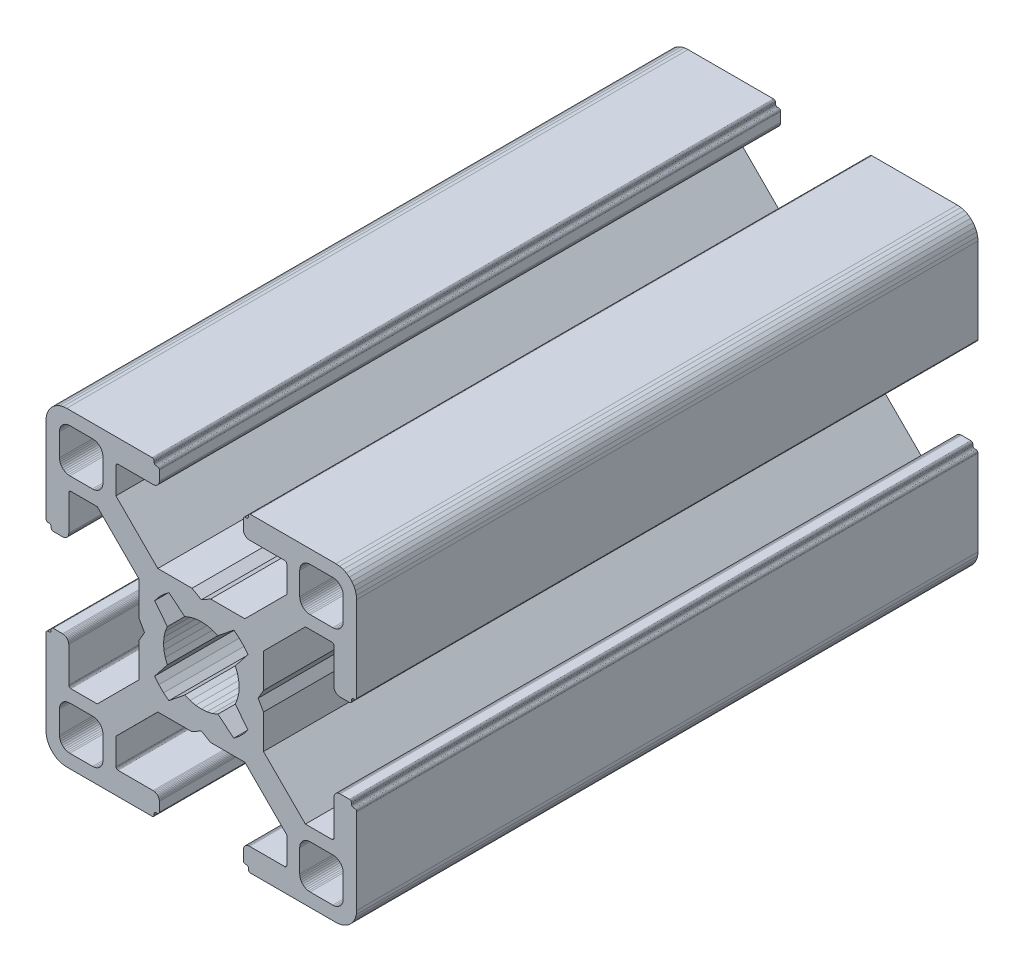
from build123d import *

# Parameters (mm, degrees)
BOSS_EXTRUDE1_DEPTH = 60


with BuildPart() as part:
    # Sketch1 → Boss-Extrude1 (new body)
    with BuildSketch(Plane.XY):
        Polygon((28.34729664, 29.969613999), (28.000000864, 29.999999329), (19.750000909, 29.999999329), (19.715268165, 29.996961355), (19.681595266, 29.987938702), (19.649999216, 29.973205179), (19.621443003, 29.953207821), (19.596790895, 29.928557575), (19.576793537, 29.899999499), (19.562061876, 29.868405312), (19.55303736, 29.834728688), (19.549999386, 29.799999669), (19.549999386, 29.699999839), (19.546961412, 29.665268958), (19.537936896, 29.631596059), (19.523203373, 29.599998146), (19.503207877, 29.571441934), (19.478557631, 29.546789825), (19.449999556, 29.526794329), (19.418403506, 29.512060806), (19.384728745, 29.503038153), (19.349999726, 29.500000179), (19.249999896, 29.500000179), (19.215267517, 29.496958527), (19.181592755, 29.487935874), (19.149996706, 29.47320235), (19.12143863, 29.453206855), (19.096788384, 29.428554746), (19.076791026, 29.399996671), (19.062057503, 29.368402484), (19.05303485, 29.334725859), (19.049996876, 29.299998703), (19.049996876, 28.39999837), (19.059110798, 28.29580945), (19.08618062, 28.194785165), (19.13038119, 28.099997016), (19.190369539, 28.014324653), (19.264324002, 27.94037019), (19.349996366, 27.88038184), (19.444784515, 27.836181271), (19.545806937, 27.809111449), (19.650010894, 27.799984574), (23.050010706, 27.799984574), (23.084741588, 27.7969466), (23.118414487, 27.787923946), (23.150012399, 27.773190423), (23.178568612, 27.753193065), (23.203220721, 27.728542819), (23.223218079, 27.699984744), (23.237949739, 27.668386831), (23.246974255, 27.634713932), (23.25001142, 27.59998608), (23.25001142, 25.049987618), (19.204474482, 20.999982084), (15.900007876, 20.999982084), (15.000008474, 20.48483404), (14.10000814, 20.999982084), (10.795543398, 20.999982084), (7.997342887, 23.801274731), (6.750011387, 25.049984589), (6.750011387, 27.599983051), (6.753049362, 27.634713932), (6.762072946, 27.668386831), (6.776805538, 27.699984744), (6.796801965, 27.728542819), (6.821454073, 27.753193065), (6.850011218, 27.773190423), (6.881607267, 27.787923946), (6.915282029, 27.7969466), (6.950011048, 27.799984574), (10.350011791, 27.799984574), (10.45420071, 27.809098497), (10.555223133, 27.836168318), (10.650011282, 27.880368888), (10.735683645, 27.940357238), (10.809638108, 28.014311701), (10.869626458, 28.099984064), (10.913827027, 28.194772213), (10.940895918, 28.295796498), (10.950010772, 28.399985417), (10.950010772, 29.299985751), (10.946974575, 29.334739239), (10.93795065, 29.368415522), (10.923215933, 29.400009153), (10.903218427, 29.428566473), (10.878566319, 29.45321765), (10.849999264, 29.473204166), (10.818403214, 29.487937689), (10.784728453, 29.496960342), (10.749999434, 29.500000179), (10.649999604, 29.500000179), (10.615270585, 29.503038153), (10.581595823, 29.512060806), (10.549999774, 29.526794329), (10.521441698, 29.546789825), (10.496791452, 29.571441934), (10.476795025, 29.599998146), (10.462061502, 29.631596059), (10.453037918, 29.665268958), (10.449999943, 29.699999839), (10.449999943, 29.799999669), (10.446961969, 29.834728688), (10.437938385, 29.868405312), (10.423205793, 29.899999499), (10.403208435, 29.928557575), (10.378557257, 29.953207821), (10.350000113, 29.973205179), (10.318404064, 29.987938702), (10.284729302, 29.996961355), (10.250000283, 29.999999329), (1.999999397, 29.999999329), (1.652702689, 29.969613999), (1.315958682, 29.879383743), (0.999999233, 29.732050374), (0.714424066, 29.532089829), (0.467910431, 29.285576195), (0.267948955, 28.999999166), (0.120614655, 28.684040532), (0.030384399, 28.34729664), (0, 28.000000864), (0, 19.750000909), (0.003037974, 19.715268165), (0.012061559, 19.681595266), (0.026795082, 19.649999216), (0.046790577, 19.621441141), (0.071442686, 19.596789032), (0.09999983, 19.576793537), (0.13159588, 19.562060013), (0.165270641, 19.55303736), (0.19999966, 19.549999386), (0.299999461, 19.549999386), (0.334728509, 19.546959549), (0.368403242, 19.537936896), (0.399999321, 19.523203373), (0.428556465, 19.503207877), (0.453208573, 19.478555769), (0.473204069, 19.449997693), (0.487937592, 19.418403506), (0.496961176, 19.384728745), (0.499999151, 19.349999726), (0.499999151, 19.249998033), (0.503038056, 19.215269014), (0.512060709, 19.181594253), (0.526794232, 19.150000066), (0.546790194, 19.121441524), (0.571441837, 19.096789882), (0.60000029, 19.076794925), (0.631595686, 19.062061999), (0.665270619, 19.053039982), (0.700000626, 19.050000801), (1.60000096, 19.050000801), (1.704189879, 19.059116587), (1.805213233, 19.086186409), (1.90000045, 19.130385115), (1.985673745, 19.190375328), (2.059627277, 19.264327928), (2.119616325, 19.350002154), (2.163816196, 19.444788441), (2.190886018, 19.545812726), (2.200000872, 19.650001645), (2.200000872, 23.050001457), (2.203039777, 23.084732338), (2.212062431, 23.118405237), (2.226795954, 23.15000315), (2.246792381, 23.178559362), (2.271443558, 23.203211471), (2.300000702, 23.223206967), (2.331596752, 23.23794049), (2.365271513, 23.246965006), (2.400001464, 23.250001117), (4.950000857, 23.250001117), (7.997332093, 20.202670812), (8.995535423, 19.204467788), (8.995535423, 15.900001182), (9.515148227, 15.00000178), (8.995535423, 14.100002378), (8.995535423, 10.795536704), (4.950000857, 6.750002138), (2.400001464, 6.750002138), (2.365271513, 6.753040112), (2.331596752, 6.762063697), (2.300000702, 6.77679722), (2.271443558, 6.796793647), (2.246792381, 6.821444824), (2.226795954, 6.850001968), (2.212062431, 6.881598018), (2.203039777, 6.915272779), (2.200000872, 6.950002729), (2.200000872, 10.350002542), (2.190896812, 10.454174265), (2.16382699, 10.555197618), (2.119627119, 10.649984836), (2.059638071, 10.735658131), (1.985684539, 10.809611663), (1.900011244, 10.869600944), (1.805224027, 10.913800582), (1.704200673, 10.940870404), (1.600011754, 10.949986189), (0.70001142, 10.949986189), (0.665281355, 10.946948596), (0.631606253, 10.937926283), (0.600010578, 10.923193954), (0.571451747, 10.903199537), (0.546799638, 10.87854836), (0.526794232, 10.850000195), (0.512060709, 10.818404146), (0.503038056, 10.784730315), (0.499999151, 10.750000365), (0.499999151, 10.650000535), (0.496961176, 10.615270585), (0.487937592, 10.581596754), (0.473204069, 10.550000705), (0.453208573, 10.521443561), (0.428556465, 10.496791452), (0.399999321, 10.476795956), (0.368403242, 10.462062433), (0.334728509, 10.453038849), (0.299999461, 10.449999943), (0.19999966, 10.449999943), (0.165270641, 10.446961969), (0.13159588, 10.437939316), (0.09999983, 10.423205793), (0.071442686, 10.403209366), (0.046790577, 10.378558189), (0.026795082, 10.350000113), (0.012061559, 10.318404064), (0.003037974, 10.284729302), (0, 10.250000283), (0, 1.999999397), (0.030384399, 1.652702689), (0.120614655, 1.315958682), (0.267948955, 0.999999233), (0.467910431, 0.714424066), (0.714424066, 0.467910431), (0.999999233, 0.267948955), (1.315958682, 0.120614655), (1.652702689, 0.030384399), (1.999999397, 0), (10.250000283, 0), (10.284729302, 0.003037974), (10.318404064, 0.012061559), (10.350000113, 0.026795082), (10.378557257, 0.046790577), (10.403208435, 0.071442686), (10.423205793, 0.09999983), (10.437938385, 0.13159588), (10.446961969, 0.165270641), (10.449999943, 0.19999966), (10.449999943, 0.300000422), (10.453037918, 0.334729441), (10.462061502, 0.368404202), (10.476795025, 0.400000252), (10.496791452, 0.428557396), (10.521441698, 0.453208573), (10.549999774, 0.473205), (10.581595823, 0.487938523), (10.615270585, 0.496961176), (10.649999604, 0.500000082), (10.749999434, 0.500000082), (10.784728453, 0.503038056), (10.818403214, 0.512060709), (10.849999264, 0.526794232), (10.878547894, 0.546800104), (10.903198606, 0.571451747), (10.923194493, 0.6000102), (10.93792742, 0.631606528), (10.946949437, 0.66528146), (10.950010772, 0.699984975), (10.950010772, 1.599985308), (10.940895918, 1.704174228), (10.913827027, 1.805197581), (10.869626458, 1.89998573), (10.809638108, 1.985658094), (10.735683645, 2.059612557), (10.650011282, 2.119600674), (10.555223133, 2.163801476), (10.45420071, 2.190870367), (10.350011791, 2.199985221), (6.950011048, 2.199985221), (6.915282029, 2.203024126), (6.881607267, 2.212046779), (6.850011218, 2.226780302), (6.821454073, 2.246776729), (6.796801965, 2.271427907), (6.776805538, 2.299985982), (6.762072946, 2.331582032), (6.753049362, 2.365256793), (6.750011387, 2.399985812), (6.750011387, 4.949985206), (9.787457566, 7.990785077), (10.795545277, 8.999985833), (14.100010019, 8.999985833), (15.000010353, 9.515133877), (15.900009756, 8.999985833), (19.204476361, 8.999985833), (20.21256413, 7.990786065), (23.25001142, 4.949988235), (23.25001142, 2.399988841), (23.246974255, 2.365256793), (23.237949739, 2.331582032), (23.223218079, 2.299985982), (23.203220721, 2.271427907), (23.178568612, 2.246776729), (23.150012399, 2.226780302), (23.118414487, 2.212046779), (23.084741588, 2.203024126), (23.050010706, 2.199985221), (19.650010894, 2.199985221), (19.545806937, 2.190883319), (19.444784515, 2.163814428), (19.349996366, 2.119613626), (19.264324002, 2.059625509), (19.190369539, 1.985671046), (19.13038119, 1.899998682), (19.08618062, 1.805210533), (19.059110798, 1.70418718), (19.049996876, 1.599998261), (19.049996876, 0.699997927), (19.053035506, 0.665268966), (19.062058795, 0.631594374), (19.076792915, 0.599998603), (19.096790813, 0.571440905), (19.121441524, 0.546790194), (19.149999978, 0.526794306), (19.181596306, 0.51206138), (19.215271238, 0.503039363), (19.249999896, 0.500000082), (19.349999726, 0.500000082), (19.384728745, 0.496961176), (19.418403506, 0.487938523), (19.449999556, 0.473205), (19.478557631, 0.453208573), (19.503207877, 0.428557396), (19.523203373, 0.400000252), (19.537936896, 0.368404202), (19.546961412, 0.334729441), (19.549999386, 0.300000422), (19.549999386, 0.19999966), (19.55303736, 0.165270641), (19.562061876, 0.13159588), (19.576793537, 0.09999983), (19.596789964, 0.071441755), (19.621442072, 0.046789646), (19.649998285, 0.02679415), (19.681594335, 0.012060627), (19.715267234, 0.003037043), (19.750000909, 0), (28.000000864, 0), (28.34729664, 0.030384399), (28.684040532, 0.120614655), (28.999999166, 0.267948955), (29.285576195, 0.467910431), (29.532089829, 0.714424066), (29.732050374, 0.999999233), (29.879383743, 1.315958682), (29.969613999, 1.652702689), (29.999999329, 1.999999397), (29.999999329, 10.250000283), (29.996974806, 10.284715361), (29.987951516, 10.318389952), (29.973217396, 10.349985723), (29.953219499, 10.378543421), (29.928568787, 10.403194133), (29.899999499, 10.423205793), (29.868405312, 10.437939316), (29.834728688, 10.446961969), (29.799999669, 10.449999943), (29.699999839, 10.449999943), (29.664909937, 10.453400043), (29.631233313, 10.462423628), (29.599637263, 10.477157151), (29.57108105, 10.497152646), (29.546427079, 10.521804755), (29.526433446, 10.550361899), (29.511699923, 10.581957949), (29.502675407, 10.615631779), (29.499637433, 10.650361729), (29.499637433, 10.750361559), (29.49697202, 10.784715548), (29.487949367, 10.818389378), (29.473215844, 10.849985428), (29.453220348, 10.878542572), (29.428568239, 10.90319468), (29.400010164, 10.923190176), (29.368415977, 10.937923699), (29.334741215, 10.946947284), (29.300012197, 10.949986189), (28.400011863, 10.949986189), (28.29581215, 10.9408876), (28.194787865, 10.913817778), (28.099999716, 10.86961814), (28.014327352, 10.809628859), (27.940374752, 10.735675327), (27.880384539, 10.650002032), (27.836185833, 10.555214814), (27.809114148, 10.454191461), (27.800000225, 10.350002542), (27.800000225, 6.950002729), (27.796962251, 6.915272779), (27.787939598, 6.881598018), (27.773206075, 6.850001968), (27.753208716, 6.821444824), (27.728558471, 6.796793647), (27.700000395, 6.77679722), (27.668404345, 6.762063697), (27.634729584, 6.753040112), (27.599998702, 6.750002138), (25.05000024, 6.750002138), (23.809199132, 7.99080223), (21.004464477, 10.795534588), (21.004464477, 14.100000262), (20.484851673, 14.999999665), (21.004464477, 15.899999067), (21.004464477, 19.204465672), (25.05000024, 23.250001117), (27.599998702, 23.250001117), (27.634729584, 23.246965006), (27.668404345, 23.23794049), (27.700000395, 23.223206967), (27.728558471, 23.203211471), (27.753208716, 23.178559362), (27.773206075, 23.15000315), (27.787939598, 23.118405237), (27.796962251, 23.084732338), (27.800000225, 23.050001457), (27.800000225, 19.650001645), (27.809114148, 19.545812726), (27.836185833, 19.444788441), (27.880384539, 19.350002154), (27.940370508, 19.264323684), (28.014323108, 19.190371084), (28.099995472, 19.130380872), (28.194783621, 19.086182165), (28.295807906, 19.059112343), (28.400001069, 19.050000801), (29.300001402, 19.050000801), (29.334730421, 19.053040638), (29.368405183, 19.062063291), (29.39999937, 19.076796814), (29.42819671, 19.097149726), (29.452848353, 19.1218023), (29.472843309, 19.150360754), (29.487576235, 19.181955219), (29.496598252, 19.215630151), (29.499637433, 19.250359227), (29.499637433, 19.35036092), (29.502675407, 19.385089939), (29.511699923, 19.4187647), (29.526433446, 19.450358887), (29.546427079, 19.478916963), (29.57108105, 19.503569071), (29.599637263, 19.523564567), (29.631233313, 19.53829809), (29.664909937, 19.547320743), (29.699999839, 19.549999386), (29.799999669, 19.549999386), (29.834728688, 19.55303736), (29.868405312, 19.562060013), (29.899999499, 19.576793537), (29.928557575, 19.596789032), (29.953207821, 19.621441141), (29.973205179, 19.649999216), (29.987938702, 19.681595266), (29.996961355, 19.715268165), (29.999999329, 19.750000909), (29.999999329, 28.000000864), (29.969613999, 28.34729664), (29.879383743, 28.684040532), (29.732050374, 28.999999166), (29.532089829, 29.285576195), (29.285576195, 29.532089829), (28.999999166, 29.732050374), (28.684040532, 29.879383743), align=None)
        Polygon((1.299998723, 25.499999523), (1.299998723, 27.699999511), (1.312309876, 27.856435627), (1.348942518, 28.009016067), (1.408992335, 28.153989464), (1.490981318, 28.287785128), (1.592892222, 28.407108039), (1.71221327, 28.50901708), (1.846008119, 28.591006994), (1.9909814, 28.651056811), (2.143563703, 28.687689453), (2.299998887, 28.699999675), (4.499998875, 28.699999675), (4.656434059, 28.687689453), (4.809016362, 28.651056811), (4.953989759, 28.591006994), (5.087784491, 28.50901708), (5.207106471, 28.407108039), (5.309016444, 28.287785128), (5.391005427, 28.153989464), (5.451056175, 28.009016067), (5.487687886, 27.856435627), (5.499999039, 27.699999511), (5.499999039, 25.499999523), (5.487687886, 25.34356527), (5.451056175, 25.190982968), (5.391005427, 25.04600957), (5.309016444, 24.912213907), (5.207106471, 24.792892858), (5.087784491, 24.690981954), (4.953989759, 24.60899204), (4.809016362, 24.548944086), (4.656434059, 24.512309581), (4.499998875, 24.499999359), (2.299998887, 24.499999359), (2.143563703, 24.512309581), (1.9909814, 24.548944086), (1.846008119, 24.60899204), (1.71221327, 24.690981954), (1.592892222, 24.792892858), (1.490981318, 24.912213907), (1.408992335, 25.04600957), (1.348942518, 25.190982968), (1.312309876, 25.34356527), align=None, mode=Mode.SUBTRACT)
        Polygon((25.34356527, 28.687689453), (25.499999523, 28.699999675), (27.699999511, 28.699999675), (27.856435627, 28.687689453), (28.009017929, 28.651056811), (28.153991327, 28.591006994), (28.28778699, 28.50901708), (28.407108039, 28.407108039), (28.50901708, 28.287785128), (28.591006994, 28.153989464), (28.651056811, 28.009016067), (28.687689453, 27.856435627), (28.700001538, 27.699999511), (28.700001538, 25.499999523), (28.687689453, 25.34356527), (28.651056811, 25.190982968), (28.591006994, 25.04600957), (28.50901708, 24.912213907), (28.407108039, 24.792892858), (28.28778699, 24.690981954), (28.153991327, 24.60899204), (28.009017929, 24.548944086), (27.856435627, 24.512309581), (27.699999511, 24.499999359), (25.499999523, 24.499999359), (25.34356527, 24.512309581), (25.190982968, 24.548944086), (25.04600957, 24.60899204), (24.912215769, 24.690981954), (24.792892858, 24.792892858), (24.690981954, 24.912213907), (24.608993903, 25.04600957), (24.548944086, 25.190982968), (24.512311444, 25.34356527), (24.500001222, 25.499999523), (24.500001222, 27.699999511), (24.512311444, 27.856435627), (24.548944086, 28.009016067), (24.608993903, 28.153989464), (24.690981954, 28.287785128), (24.792892858, 28.407108039), (24.912215769, 28.50901708), (25.04600957, 28.591006994), (25.190982968, 28.651056811), align=None, mode=Mode.SUBTRACT)
        Polygon((14.999999665, 18.649999052), (15.550030395, 18.608318642), (16.087498516, 18.484227359), (16.600128263, 18.280562013), (18.13592948, 19.518401474), (18.644984812, 19.11874488), (19.103571773, 18.662061542), (19.505336881, 18.154669553), (18.280562013, 16.600130126), (18.484227359, 16.087498516), (18.608318642, 15.550030395), (18.649999052, 14.999999665), (18.608318642, 14.449968934), (18.484227359, 13.912500814), (18.280562013, 13.399870135), (19.505336881, 11.845329776), (19.103571773, 11.337937787), (18.644984812, 10.881252587), (18.13592948, 10.481598787), (16.600128263, 11.719437316), (16.087498516, 11.515771039), (15.550030395, 11.391680688), (14.999999665, 11.349999346), (14.449968934, 11.391680688), (13.912500814, 11.515771039), (13.399870135, 11.719437316), (11.864069849, 10.481598787), (11.355013587, 10.881252587), (10.896427557, 11.337937787), (10.494662449, 11.845329776), (11.719438247, 13.399870135), (11.515771039, 13.912500814), (11.391680688, 14.449968934), (11.349999346, 14.999999665), (11.391680688, 15.550030395), (11.515771039, 16.087498516), (11.719438247, 16.600130126), (10.494662449, 18.154669553), (10.896427557, 18.662061542), (11.355013587, 19.11874488), (11.864069849, 19.518401474), (13.399870135, 18.280562013), (13.912500814, 18.484227359), (14.449968934, 18.608318642), align=None, mode=Mode.SUBTRACT)
        Polygon((4.499998875, 1.299999771), (2.299998887, 1.299999771), (2.143563703, 1.312310807), (1.9909814, 1.348942518), (1.846008119, 1.408992335), (1.71221327, 1.490982249), (1.592892222, 1.592892222), (1.490981318, 1.712214202), (1.408992335, 1.846008934), (1.348942518, 1.990982331), (1.312309876, 2.143564634), (1.299998723, 2.299998887), (1.299998723, 4.499999806), (1.312309876, 4.656434059), (1.348942518, 4.809017293), (1.408992335, 4.95399069), (1.490981318, 5.087785423), (1.592892222, 5.207106471), (1.71221327, 5.309017375), (1.846008119, 5.391006358), (1.9909814, 5.451056175), (2.143563703, 5.487688817), (2.299998887, 5.49999997), (4.499998875, 5.49999997), (4.656434059, 5.487688817), (4.809016362, 5.451056175), (4.953989759, 5.391006358), (5.087784491, 5.309017375), (5.207106471, 5.207106471), (5.309016444, 5.087785423), (5.391005427, 4.95399069), (5.451056175, 4.809017293), (5.487687886, 4.656434059), (5.499999039, 4.499999806), (5.499999039, 2.299998887), (5.487687886, 2.143564634), (5.451056175, 1.990982331), (5.391005427, 1.846008934), (5.309016444, 1.712214202), (5.207106471, 1.592892222), (5.087784491, 1.490982249), (4.953989759, 1.408992335), (4.809016362, 1.348942518), (4.656434059, 1.312310807), align=None, mode=Mode.SUBTRACT)
        Polygon((27.699999511, 1.299999771), (25.499999523, 1.299999771), (25.34356527, 1.312310807), (25.190982968, 1.348942518), (25.04600957, 1.408992335), (24.912215769, 1.490982249), (24.792892858, 1.592892222), (24.690981954, 1.712214202), (24.608993903, 1.846008934), (24.548944086, 1.990982331), (24.512311444, 2.143564634), (24.500001222, 2.299998887), (24.500001222, 4.499999806), (24.512311444, 4.656434059), (24.548944086, 4.809017293), (24.608993903, 4.95399069), (24.690981954, 5.087785423), (24.792892858, 5.207106471), (24.912215769, 5.309017375), (25.04600957, 5.391006358), (25.190982968, 5.451056175), (25.34356527, 5.487688817), (25.499999523, 5.49999997), (27.699999511, 5.49999997), (27.856435627, 5.487688817), (28.009017929, 5.451056175), (28.153991327, 5.391006358), (28.28778699, 5.309017375), (28.407108039, 5.207106471), (28.50901708, 5.087785423), (28.591006994, 4.95399069), (28.651056811, 4.809017293), (28.687689453, 4.656434059), (28.700001538, 4.499999806), (28.700001538, 2.299998887), (28.687689453, 2.143564634), (28.651056811, 1.990982331), (28.591006994, 1.846008934), (28.50901708, 1.712214202), (28.407108039, 1.592892222), (28.28778699, 1.490982249), (28.153991327, 1.408992335), (28.009017929, 1.348942518), (27.856435627, 1.312310807), align=None, mode=Mode.SUBTRACT)
    extrude(amount=-BOSS_EXTRUDE1_DEPTH)


solid = part.part
